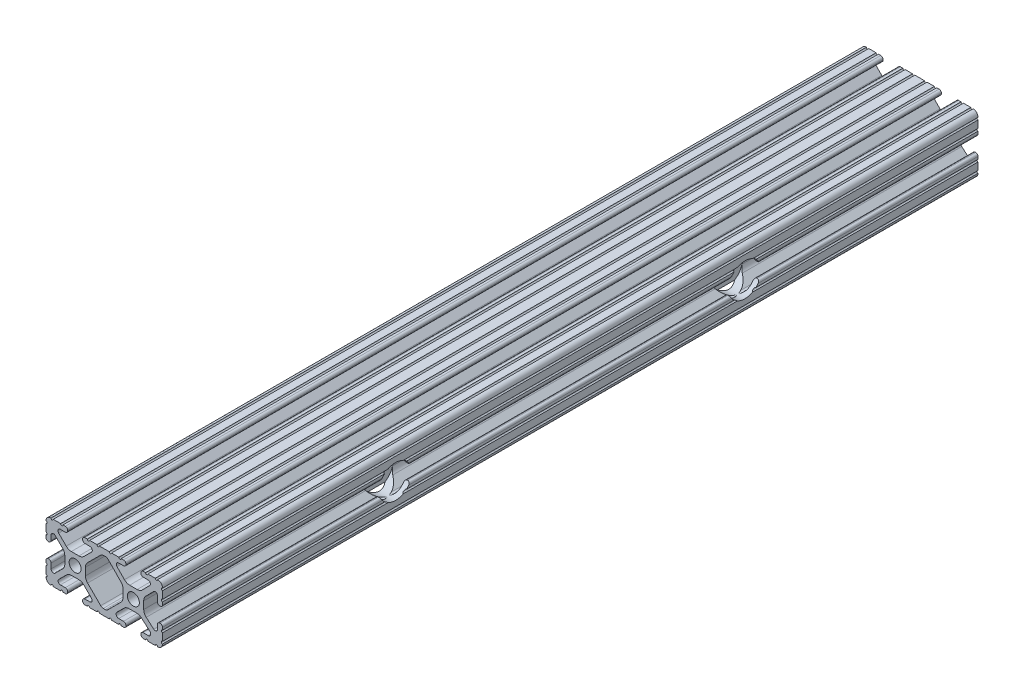
from build123d import *

# Parameters (mm, degrees)
SKETCH1_R                                            = 2.6035
BOSS_EXTRUDE1_DEPTH                                  = 177.8
CBORE_FOR_1_4_BINDING_HEAD_MACHINE_SCREW_D           = 6.7564
CBORE_FOR_1_4_BINDING_HEAD_MACHINE_SCREW_CBORE_D     = 14.2875
CBORE_FOR_1_4_BINDING_HEAD_MACHINE_SCREW_CBORE_DEPTH = 8.255


with BuildPart() as part:
    # Sketch1 → Boss-Extrude1 (new body, symmetric)
    with BuildSketch(Plane.XY):
        with BuildLine():
            Line((18.01710265, 12.7), (16.98745015, 12.7))
            ThreePointArc((16.98745015, 12.7), (16.245730386, 12.392769614), (15.9385, 11.65104985))
            Line((15.9385, 11.65104985), (15.9385, 11.53922))
            ThreePointArc((15.9385, 11.53922), (16.245750844, 10.797450844), (16.98752, 10.4902))
            Line((16.98752, 10.4902), (19.116384363, 10.4902))
            ThreePointArc((19.116384363, 10.4902), (20.052502933, 9.869096983), (19.844087081, 8.765172272))
            Line((19.844087081, 8.765172272), (16.618993479, 5.455112286))
            ThreePointArc((16.618993479, 5.455112286), (15.578994274, 4.745442459), (14.344932584, 4.4958))
            Line((14.344932584, 4.4958), (11.083317835, 4.4958))
            ThreePointArc((11.083317835, 4.4958), (9.854330953, 4.743306833), (8.816955189, 5.447238587))
            Line((8.816955189, 5.447238587), (5.564154119, 8.762652677))
            ThreePointArc((5.564154119, 8.762652677), (5.352591412, 9.867473037), (6.289393385, 10.4902))
            Line((6.289393385, 10.4902), (8.41248, 10.4902))
            ThreePointArc((8.41248, 10.4902), (9.154249156, 10.797450844), (9.4615, 11.53922))
            Line((9.4615, 11.53922), (9.4615, 11.65104985))
            ThreePointArc((9.4615, 11.65104985), (9.154269614, 12.392769614), (8.41254985, 12.7))
            Line((8.41254985, 12.7), (7.38288465, 12.7))
            ThreePointArc((7.38288465, 12.7), (6.87488465, 12.192), (6.36688465, 12.7))
            Line((6.36688465, 12.7), (3.14958095, 12.7))
            ThreePointArc((3.14958095, 12.7), (2.64158095, 12.192), (2.13358095, 12.7))
            Line((2.13358095, 12.7), (-2.13358095, 12.7))
            ThreePointArc((-2.13358095, 12.7), (-2.64158095, 12.192), (-3.14958095, 12.7))
            Line((-3.14958095, 12.7), (-6.36689735, 12.7))
            ThreePointArc((-6.36689735, 12.7), (-6.87489735, 12.192), (-7.38289735, 12.7))
            Line((-7.38289735, 12.7), (-8.41254985, 12.7))
            ThreePointArc((-8.41254985, 12.7), (-9.154269614, 12.392769614), (-9.4615, 11.65104985))
            Line((-9.4615, 11.65104985), (-9.4615, 11.53922))
            ThreePointArc((-9.4615, 11.53922), (-9.154249156, 10.797450844), (-8.41248, 10.4902))
            Line((-8.41248, 10.4902), (-6.283641037, 10.4902))
            ThreePointArc((-6.283641037, 10.4902), (-5.297291557, 9.829633109), (-5.532576693, 8.666071843))
            Line((-5.532576693, 8.666071843), (-8.809985098, 5.416263103))
            ThreePointArc((-8.809985098, 5.416263103), (-9.836720513, 4.734920264), (-11.045536121, 4.4958))
            Line((-11.045536121, 4.4958), (-14.354463879, 4.4958))
            ThreePointArc((-14.354463879, 4.4958), (-15.563279487, 4.734920264), (-16.590014902, 5.416263103))
            Line((-16.590014902, 5.416263103), (-19.867423307, 8.666071843))
            ThreePointArc((-19.867423307, 8.666071843), (-20.102708443, 9.829633109), (-19.116358963, 10.4902))
            Line((-19.116358963, 10.4902), (-16.98752, 10.4902))
            ThreePointArc((-16.98752, 10.4902), (-16.245750844, 10.797450844), (-15.9385, 11.53922))
            Line((-15.9385, 11.53922), (-15.9385, 11.65104985))
            ThreePointArc((-15.9385, 11.65104985), (-16.245730386, 12.392769614), (-16.98745015, 12.7))
            Line((-16.98745015, 12.7), (-18.01711535, 12.7))
            ThreePointArc((-18.01711535, 12.7), (-18.52511535, 12.192), (-19.03311535, 12.7))
            Line((-19.03311535, 12.7), (-22.2504, 12.7))
            ThreePointArc((-22.2504, 12.7), (-22.758323491, 12.192000006), (-23.266399977, 12.699846982))
            ThreePointArc((-23.266399977, 12.699846982), (-24.782522516, 12.082522516), (-25.399846982, 10.566399977))
            ThreePointArc((-25.399846982, 10.566399977), (-24.892000006, 10.058323491), (-25.4, 9.5504))
            Line((-25.4, 9.5504), (-25.4, 6.3330836))
            ThreePointArc((-25.4, 6.3330836), (-24.892, 5.8250836), (-25.4, 5.3170836))
            Line((-25.4, 5.3170836), (-25.4, 4.237520184))
            ThreePointArc((-25.4, 4.237520184), (-25.107393763, 3.531106237), (-24.400979816, 3.2385))
            Line((-24.400979816, 3.2385), (-24.23922, 3.2385))
            ThreePointArc((-24.23922, 3.2385), (-23.497450844, 3.545750844), (-23.1902, 4.28752))
            Line((-23.1902, 4.28752), (-23.1902, 6.334741132))
            ThreePointArc((-23.1902, 6.334741132), (-22.556026952, 7.286023527), (-21.434002553, 7.066535717))
            Line((-21.434002553, 7.066535717), (-18.147950853, 3.808156468))
            ThreePointArc((-18.147950853, 3.808156468), (-17.452759693, 2.774838327), (-17.208501877, 1.553619571))
            Line((-17.208501877, 1.553619571), (-17.208501877, -1.695179196))
            ThreePointArc((-17.208501877, -1.695179196), (-17.450738657, -2.911536421), (-18.140486065, -3.942289578))
            Line((-18.140486065, -3.942289578), (-21.431579576, -7.227386226))
            ThreePointArc((-21.431579576, -7.227386226), (-22.55444896, -7.449940594), (-23.1902, -6.498002195))
            Line((-23.1902, -6.498002195), (-23.1902, -4.28752))
            ThreePointArc((-23.1902, -4.28752), (-23.497450844, -3.545750844), (-24.23922, -3.2385))
            Line((-24.23922, -3.2385), (-24.35098, -3.2385))
            ThreePointArc((-24.35098, -3.2385), (-25.092749156, -3.545750844), (-25.4, -4.28752))
            Line((-25.4, -4.28752), (-25.4, -5.3171344))
            ThreePointArc((-25.4, -5.3171344), (-24.892, -5.8251344), (-25.4, -6.3331344))
            Line((-25.4, -6.3331344), (-25.4, -9.5504))
            ThreePointArc((-25.4, -9.5504), (-24.892000006, -10.058323491), (-25.399846982, -10.566399977))
            ThreePointArc((-25.399846982, -10.566399977), (-24.782522516, -12.082522516), (-23.266399977, -12.699846982))
            ThreePointArc((-23.266399977, -12.699846982), (-22.758323491, -12.192000006), (-22.2504, -12.7))
            Line((-22.2504, -12.7), (-19.03308995, -12.7))
            ThreePointArc((-19.03308995, -12.7), (-18.52508995, -12.192), (-18.01708995, -12.7))
            Line((-18.01708995, -12.7), (-16.9874692, -12.7))
            ThreePointArc((-16.9874692, -12.7), (-16.245700044, -12.392749156), (-15.9384492, -11.65098))
            Line((-15.9384492, -11.65098), (-15.9384492, -11.53922))
            ThreePointArc((-15.9384492, -11.53922), (-16.245700044, -10.797450844), (-16.9874692, -10.4902))
            Line((-16.9874692, -10.4902), (-19.116358963, -10.4902))
            ThreePointArc((-19.116358963, -10.4902), (-20.055197748, -9.862578342), (-19.834124023, -8.755124678))
            Line((-19.834124023, -8.755124678), (-16.49660751, -5.423689618))
            ThreePointArc((-16.49660751, -5.423689618), (-15.467274017, -4.736928798), (-14.253591699, -4.4958))
            Line((-14.253591699, -4.4958), (-11.146408301, -4.4958))
            ThreePointArc((-11.146408301, -4.4958), (-9.932725983, -4.736928798), (-8.90339249, -5.423689618))
            Line((-8.90339249, -5.423689618), (-5.565875977, -8.755124678))
            ThreePointArc((-5.565875977, -8.755124678), (-5.344802252, -9.862578342), (-6.283641037, -10.4902))
            Line((-6.283641037, -10.4902), (-8.4125308, -10.4902))
            ThreePointArc((-8.4125308, -10.4902), (-9.154299956, -10.797450844), (-9.4615508, -11.53922))
            Line((-9.4615508, -11.53922), (-9.4615508, -11.65098))
            ThreePointArc((-9.4615508, -11.65098), (-9.154299956, -12.392749156), (-8.4125308, -12.7))
            Line((-8.4125308, -12.7), (-7.38287195, -12.7))
            ThreePointArc((-7.38287195, -12.7), (-6.87487195, -12.192), (-6.36687195, -12.7))
            Line((-6.36687195, -12.7), (-3.14960635, -12.7))
            ThreePointArc((-3.14960635, -12.7), (-2.64160635, -12.192), (-2.13360635, -12.7))
            Line((-2.13360635, -12.7), (2.13360635, -12.7))
            ThreePointArc((2.13360635, -12.7), (2.64159365, -12.1920127), (3.14958095, -12.7))
            Line((3.14958095, -12.7), (6.36691005, -12.7))
            ThreePointArc((6.36691005, -12.7), (6.87491005, -12.192), (7.38291005, -12.7))
            Line((7.38291005, -12.7), (8.4125308, -12.7))
            ThreePointArc((8.4125308, -12.7), (9.154299956, -12.392749156), (9.4615508, -11.65098))
            Line((9.4615508, -11.65098), (9.4615508, -11.53922))
            ThreePointArc((9.4615508, -11.53922), (9.154299956, -10.797450844), (8.4125308, -10.4902))
            Line((8.4125308, -10.4902), (6.289393385, -10.4902))
            ThreePointArc((6.289393385, -10.4902), (5.231590322, -9.783049717), (5.480677245, -8.535265862))
            Line((5.480677245, -8.535265862), (8.597933595, -5.423689618))
            ThreePointArc((8.597933595, -5.423689618), (9.627267088, -4.736928798), (10.840949406, -4.4958))
            Line((10.840949406, -4.4958), (14.102564155, -4.4958))
            ThreePointArc((14.102564155, -4.4958), (15.215927525, -4.697410182), (16.187895372, -5.276636531))
            Line((16.187895372, -5.276636531), (19.868247549, -8.482246082))
            ThreePointArc((19.868247549, -8.482246082), (20.188435806, -9.746879864), (19.116384363, -10.4902))
            Line((19.116384363, -10.4902), (16.9874692, -10.4902))
            ThreePointArc((16.9874692, -10.4902), (16.245700044, -10.797450844), (15.9384492, -11.53922))
            Line((15.9384492, -11.53922), (15.9384492, -11.65098))
            ThreePointArc((15.9384492, -11.65098), (16.245700044, -12.392749156), (16.9874692, -12.7))
            Line((16.9874692, -12.7), (18.01710265, -12.7))
            ThreePointArc((18.01710265, -12.7), (18.52510265, -12.192), (19.03310265, -12.7))
            Line((19.03310265, -12.7), (22.2504, -12.7))
            ThreePointArc((22.2504, -12.7), (22.758323491, -12.192000006), (23.266399977, -12.699846982))
            ThreePointArc((23.266399977, -12.699846982), (24.782522516, -12.082522516), (25.399846982, -10.566399977))
            ThreePointArc((25.399846982, -10.566399977), (24.892000006, -10.058323492), (25.4, -9.550400001))
            Line((25.4, -9.550400001), (25.4, -6.333083592))
            ThreePointArc((25.4, -6.333083592), (24.892000001, -5.825083593), (25.4, -5.317083593))
            Line((25.4, -5.317083593), (25.4, -4.237520184))
            ThreePointArc((25.4, -4.237520184), (25.107393763, -3.531106237), (24.400979816, -3.2385))
            Line((24.400979816, -3.2385), (24.189220184, -3.2385))
            ThreePointArc((24.189220184, -3.2385), (23.482806237, -3.531106237), (23.1902, -4.237520184))
            Line((23.1902, -4.237520184), (23.1902, -6.155876159))
            ThreePointArc((23.1902, -6.155876159), (22.62232736, -7.038258539), (21.583974541, -6.886926384))
            Line((21.583974541, -6.886926384), (18.29817066, -4.024970844))
            ThreePointArc((18.29817066, -4.024970844), (17.493730985, -2.946044689), (17.208501877, -1.630807374))
            Line((17.208501877, -1.630807374), (17.208501877, 1.630807374))
            ThreePointArc((17.208501877, 1.630807374), (17.442348332, 2.82673414), (18.109440981, 3.846495088))
            Line((18.109440981, 3.846495088), (21.526346532, 7.353420386))
            ThreePointArc((21.526346532, 7.353420386), (22.585896263, 7.574939077), (23.1902, 6.676867167))
            Line((23.1902, 6.676867167), (23.1902, 4.237520184))
            ThreePointArc((23.1902, 4.237520184), (23.482806237, 3.531106237), (24.189220184, 3.2385))
            Line((24.189220184, 3.2385), (24.400979816, 3.2385))
            ThreePointArc((24.400979816, 3.2385), (25.107393763, 3.531106237), (25.4, 4.237520184))
            Line((25.4, 4.237520184), (25.4, 5.3170836))
            ThreePointArc((25.4, 5.3170836), (24.891949193, 5.825134407), (25.4, 6.333185215))
            Line((25.4, 6.333185215), (25.4, 9.550400015))
            ThreePointArc((25.4, 9.550400015), (24.892000013, 10.058323498), (25.399846982, 10.566399977))
            ThreePointArc((25.399846982, 10.566399977), (24.782522516, 12.082522516), (23.266399977, 12.699846982))
            ThreePointArc((23.266399977, 12.699846982), (22.758323491, 12.192000006), (22.2504, 12.7))
            Line((22.2504, 12.7), (19.03310265, 12.7))
            ThreePointArc((19.03310265, 12.7), (18.52510265, 12.192), (18.01710265, 12.7))
        make_face()
        with Locations((-12.7, 0)):
            Circle(SKETCH1_R, mode=Mode.SUBTRACT)
        with Locations((12.7, 0)):
            Circle(SKETCH1_R, mode=Mode.SUBTRACT)
        with BuildLine():
            Line((-7.259513935, -3.869413038), (-1.545748891, -9.572766749))
            ThreePointArc((-1.545748891, -9.572766749), (-1.035199478, -9.913400116), (-0.433213048, -10.033))
            Line((-0.433213048, -10.033), (0.433213048, -10.033))
            ThreePointArc((0.433213048, -10.033), (1.035199478, -9.913400116), (1.545748891, -9.572766749))
            Line((1.545748891, -9.572766749), (7.259513935, -3.869413038))
            ThreePointArc((7.259513935, -3.869413038), (7.949261343, -2.838659881), (8.191498123, -1.622302656))
            Line((8.191498123, -1.622302656), (8.191498123, 1.622302656))
            ThreePointArc((8.191498123, 1.622302656), (7.955573352, 2.823327967), (7.282860769, 3.845864069))
            Line((7.282860769, 3.845864069), (1.675572808, 9.561086461))
            ThreePointArc((1.675572808, 9.561086461), (1.161034429, 9.910236611), (0.551456936, 10.033))
            Line((0.551456936, 10.033), (-0.395199982, 10.033))
            ThreePointArc((-0.395199982, 10.033), (-0.994772524, 9.914396349), (-1.50403329, 9.576450301))
            Line((-1.50403329, 9.576450301), (-7.252049147, 3.876839553))
            ThreePointArc((-7.252049147, 3.876839553), (-7.947240307, 2.843521412), (-8.191498123, 1.622302656))
            Line((-8.191498123, 1.622302656), (-8.191498123, -1.622302656))
            ThreePointArc((-8.191498123, -1.622302656), (-7.949261343, -2.838659881), (-7.259513935, -3.869413038))
        make_face(mode=Mode.SUBTRACT)
    extrude(amount=BOSS_EXTRUDE1_DEPTH, both=True)

    # CBORE for 1/4 Binding Head Machine Screw1 (through all)
    with Locations(Plane(origin=(25.4, 0, 0), x_dir=(0, 0, -1), z_dir=(1, 0, 0))):
        with Locations((-76.2, 0), (76.2, 0)):
            CounterBoreHole(CBORE_FOR_1_4_BINDING_HEAD_MACHINE_SCREW_D / 2, CBORE_FOR_1_4_BINDING_HEAD_MACHINE_SCREW_CBORE_D / 2, CBORE_FOR_1_4_BINDING_HEAD_MACHINE_SCREW_CBORE_DEPTH)


solid = part.part
